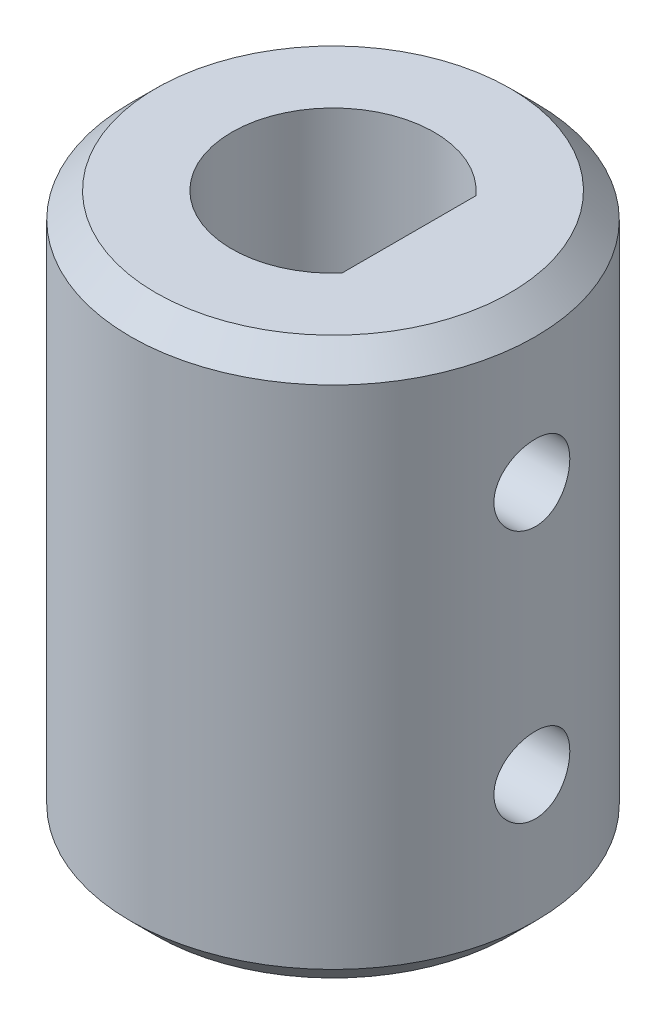
from build123d import *

# Parameters (mm, degrees)
SKETCH1_R           = 8
BOSS_EXTRUDE1_DEPTH = 22
CUT_EXTRUDE3_DEPTH  = 12
CUT_EXTRUDE4_DEPTH  = 10
CHAMFER1_SIZE       = 1
CUT_EXTRUDE5_REACH  = 18
SKETCH4_R           = 1.5


with BuildPart() as part:
    # Sketch1 → Boss-Extrude1 (new body)
    with BuildSketch(Plane(origin=(0, 0, 0), x_dir=(1, 0, 0), z_dir=(0, 1, 0))):
        Circle(SKETCH1_R)
    extrude(amount=BOSS_EXTRUDE1_DEPTH)

    # Sketch3 → Cut-Extrude3 (cut)
    with BuildSketch(Plane.XZ):
        with BuildLine():
            Line((3, 2.645751311), (3, -2.645751311))
            ThreePointArc((3, -2.645751311), (-4, 0), (3, 2.645751311))
        make_face()
    extrude(amount=-CUT_EXTRUDE3_DEPTH, mode=Mode.SUBTRACT)

    # Sketch2 → Cut-Extrude4 (cut)
    with BuildSketch(Plane(origin=(0, 22, 0), x_dir=(1, 0, 0), z_dir=(0, 1, 0))):
        with BuildLine():
            Line((3, 2.645751311), (3, -2.645751311))
            ThreePointArc((3, -2.645751311), (1.645751311, -3.645751311), (0, -4))
            ThreePointArc((0, -4), (-4, 0), (0, 4))
            ThreePointArc((0, 4), (1.645751311, 3.645751311), (3, 2.645751311))
        make_face()
    extrude(amount=-CUT_EXTRUDE4_DEPTH, mode=Mode.SUBTRACT)

    # Chamfer1
    chamfer1_edges = [part.edges().sort_by_distance(p)[0] for p in [
        (-8, 0, 0),
        (-8, 22, 0),
    ]]
    chamfer(chamfer1_edges, length=CHAMFER1_SIZE)

    # Sketch4 → Cut-Extrude5 (cut, up to next)
    with BuildSketch(Plane(origin=(8, 0, 0), x_dir=(0, 0, -1), z_dir=(1, 0, 0)), mode=Mode.PRIVATE) as cut_extrude5_sk1:
        with Locations((0, 16)):
            Circle(SKETCH4_R)
    cut_extrude5_tool1 = extrude(cut_extrude5_sk1.sketch, amount=-CUT_EXTRUDE5_REACH, mode=Mode.PRIVATE) & part.part
    add(cut_extrude5_tool1.solids().sort_by_distance((8, 16, 0))[0], mode=Mode.SUBTRACT)
    # Sketch4 → Cut-Extrude5 (cut, up to next)
    with BuildSketch(Plane(origin=(8, 0, 0), x_dir=(0, 0, -1), z_dir=(1, 0, 0)), mode=Mode.PRIVATE) as cut_extrude5_sk2:
        with Locations((0, 6)):
            Circle(SKETCH4_R)
    cut_extrude5_tool2 = extrude(cut_extrude5_sk2.sketch, amount=-CUT_EXTRUDE5_REACH, mode=Mode.PRIVATE) & part.part
    add(cut_extrude5_tool2.solids().sort_by_distance((8, 6, 0))[0], mode=Mode.SUBTRACT)


solid = part.part
